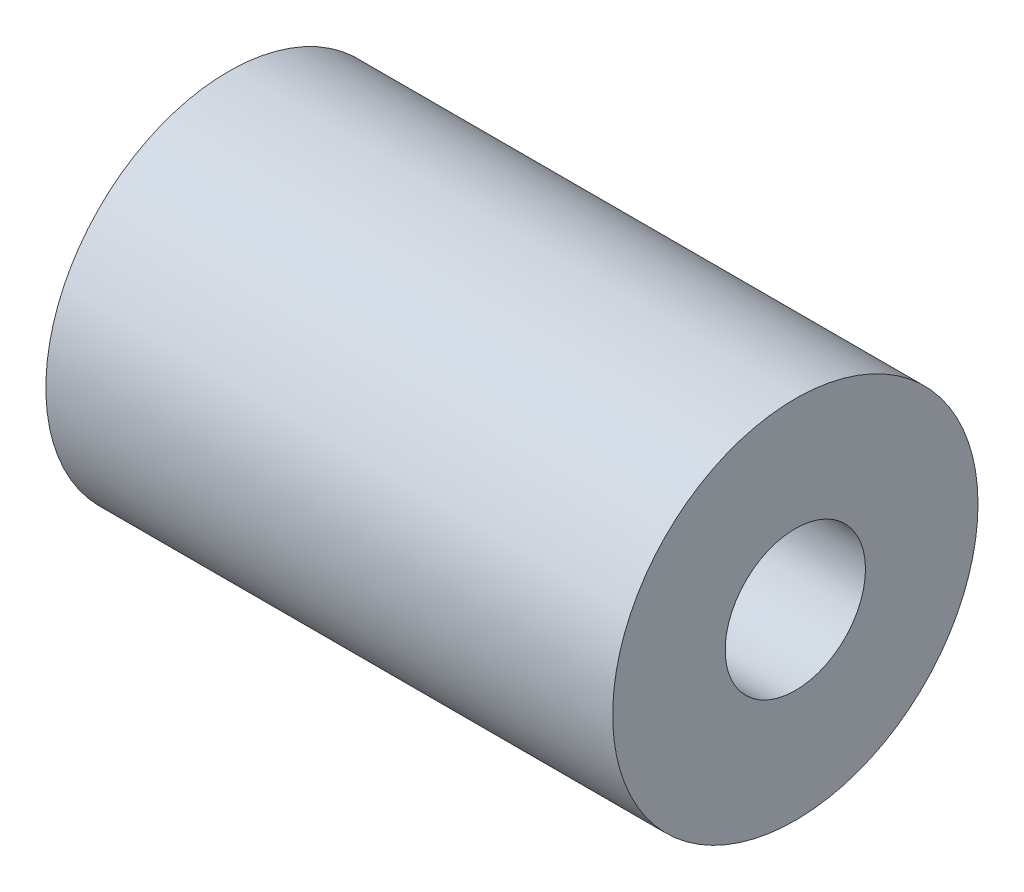
from build123d import *

# Parameters (mm, degrees)
SKETCH1_R           = 8.2677
SKETCH1_R_2         = 3.175
BOSS_EXTRUDE1_DEPTH = 12.827


with BuildPart() as part:
    # Sketch1 → Boss-Extrude1 (new body, symmetric)
    with BuildSketch(Plane(origin=(0, 0, 0), x_dir=(0, 0, -1), z_dir=(1, 0, 0))):
        Circle(SKETCH1_R)
        Circle(SKETCH1_R_2, mode=Mode.SUBTRACT)
    extrude(amount=BOSS_EXTRUDE1_DEPTH, both=True)


solid = part.part
